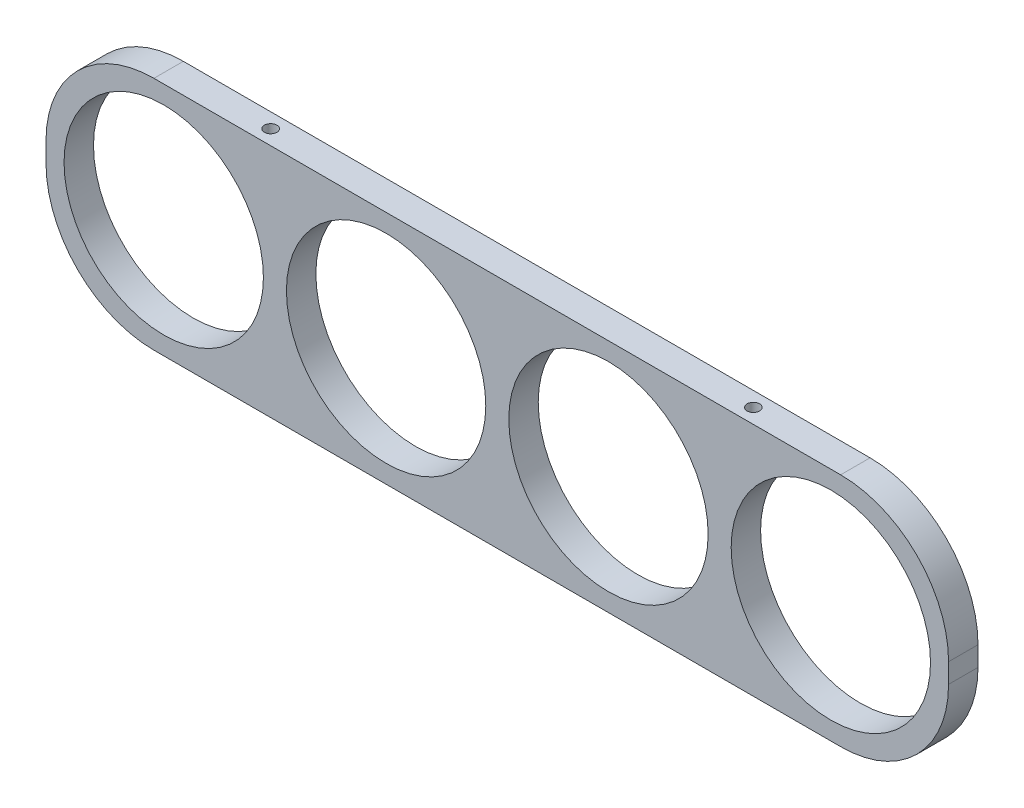
from build123d import *

# Parameters (mm, degrees)
SKETCH1_W                  = 292.1
SKETCH1_H                  = 76.2
BOSS_EXTRUDE1_DEPTH        = 4.7625
SKETCH2_R                  = 32.258
CUT_EXTRUDE1_DEPTH         = 10.525
FILLET1_R                  = 34.925
F_10_32_TAPPED_HOLE2_D     = 4.0386
F_10_32_TAPPED_HOLE2_DEPTH = 19.05
F_10_32_TAPPED_HOLE2_TIP   = 1.213317848


with BuildPart() as part:
    # Sketch1 → Boss-Extrude1 (new body, symmetric)
    with BuildSketch(Plane.XY):
        Rectangle(SKETCH1_W, SKETCH1_H)
    extrude(amount=BOSS_EXTRUDE1_DEPTH, both=True)

    # Sketch2 → Cut-Extrude1 (cut, through all)
    with BuildSketch(Plane.XY.offset(4.7625)):
        with Locations((-107.95, 0)):
            Circle(SKETCH2_R)
        with Locations((-35.983333333, 0)):
            Circle(SKETCH2_R)
        with Locations((35.983333333, 0)):
            Circle(SKETCH2_R)
        with Locations((107.95, 0)):
            Circle(SKETCH2_R)
    extrude(amount=-CUT_EXTRUDE1_DEPTH, mode=Mode.SUBTRACT)

    # Fillet1
    fillet1_edges = [part.edges().sort_by_distance(p)[0] for p in [
        (-146.05, 38.1, 0),
        (146.05, 38.1, 0),
        (146.05, -38.1, 0),
        (-146.05, -38.1, 0),
    ]]
    fillet(fillet1_edges, radius=FILLET1_R)

    # #10-32 Tapped Hole2
    with Locations(Plane(origin=(0, 38.1, 0), x_dir=(1, 0, 0), z_dir=(0, 1, 0))):
        with Locations((-78.105, 0), (78.105, 0)):
            Hole(F_10_32_TAPPED_HOLE2_D / 2, depth=F_10_32_TAPPED_HOLE2_DEPTH)
            with Locations((0, 0, -(F_10_32_TAPPED_HOLE2_DEPTH + F_10_32_TAPPED_HOLE2_TIP / 2))):  # 118° drill point
                Cone(0, F_10_32_TAPPED_HOLE2_D / 2, F_10_32_TAPPED_HOLE2_TIP, mode=Mode.SUBTRACT)


solid = part.part
